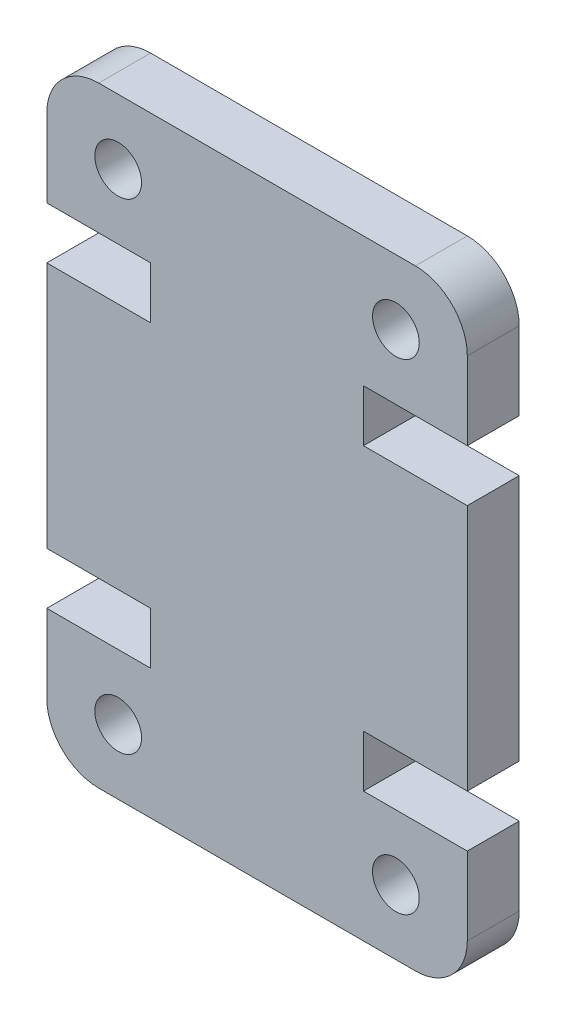
from build123d import *

# Parameters (mm, degrees)
SKETCH1_R           = 0.9
BOSS_EXTRUDE1_DEPTH = 2


with BuildPart() as part:
    # Sketch1 → Boss-Extrude1 (new body)
    with BuildSketch(Plane.XY):
        with BuildLine():
            Line((16.2, 5), (16.2, 2))
            ThreePointArc((16.2, 2), (15.614213562, 0.585786438), (14.2, 0))
            Line((14.2, 0), (2, 0))
            ThreePointArc((2, 0), (0.585786438, 0.585786438), (0, 2))
            Line((0, 2), (0, 5))
            Line((0, 5), (4, 5))
            Line((4, 5), (4, 7))
            Line((4, 7), (0, 7))
            Line((0, 7), (0, 16.525))
            Line((0, 16.525), (4, 16.525))
            Line((4, 16.525), (4, 18.525))
            Line((4, 18.525), (0, 18.525))
            Line((0, 18.525), (0, 21.525))
            ThreePointArc((0, 21.525), (0.585786438, 22.939213562), (2, 23.525))
            Line((2, 23.525), (14.2, 23.525))
            ThreePointArc((14.2, 23.525), (15.614213562, 22.939213562), (16.2, 21.525))
            Line((16.2, 21.525), (16.2, 18.525))
            Line((16.2, 18.525), (12.2, 18.525))
            Line((12.2, 18.525), (12.2, 16.525))
            Line((12.2, 16.525), (16.2, 16.525))
            Line((16.2, 16.525), (16.2, 7))
            Line((16.2, 7), (12.2, 7))
            Line((12.2, 7), (12.2, 5))
            Line((12.2, 5), (16.2, 5))
        make_face()
        with Locations((13.45, 2.5)):
            Circle(SKETCH1_R, mode=Mode.SUBTRACT)
        with Locations((2.75, 21.025)):
            Circle(SKETCH1_R, mode=Mode.SUBTRACT)
        with Locations((13.45, 21.025)):
            Circle(SKETCH1_R, mode=Mode.SUBTRACT)
        with Locations((2.75, 2.5)):
            Circle(SKETCH1_R, mode=Mode.SUBTRACT)
    extrude(amount=BOSS_EXTRUDE1_DEPTH)


solid = part.part
